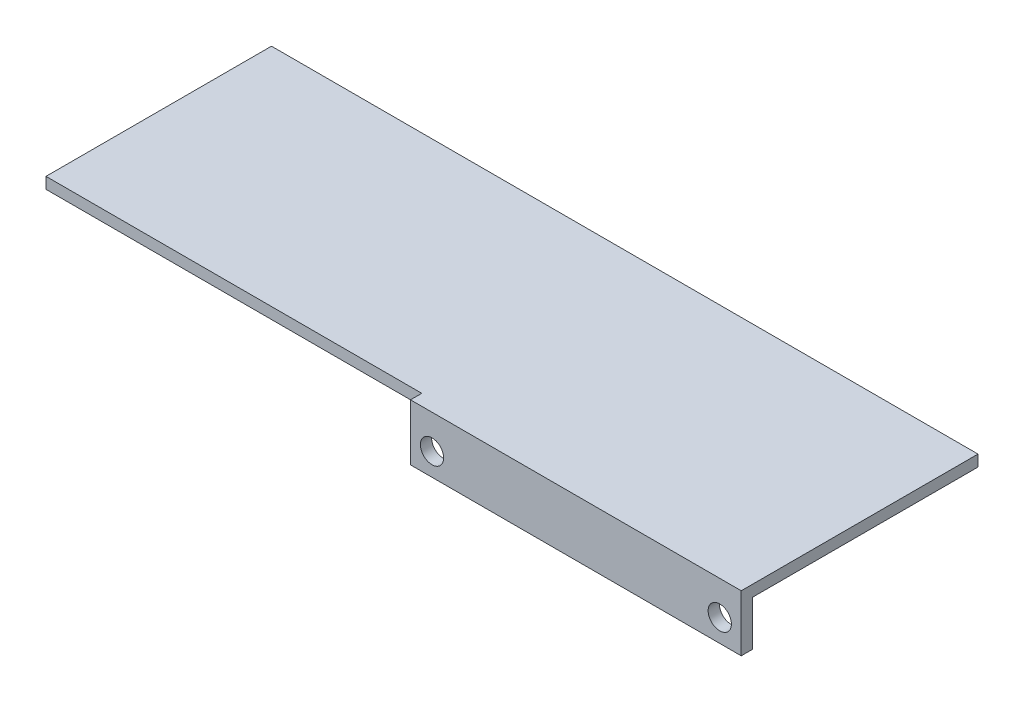
from build123d import *

# Parameters (mm, degrees)
SKETCH_1_W      = 44
SKETCH_1_H      = 6
SKETCH_1_R      = 1.55
EXTRUDE_1_DEPTH = 1.5
SKETCH_2_W      = 44
SKETCH_2_H      = 1.5
EXTRUDE_2_DEPTH = 1.5
SKETCH_4_W      = 44
SKETCH_4_H      = 1.5
EXTRUDE_3_DEPTH = 30
SKETCH_6_W      = 30
SKETCH_6_H      = 1.5
EXTRUDE_4_DEPTH = 50


with BuildPart() as part:
    # 草图1 → 凸台-拉伸1 (new body)
    with BuildSketch(Plane.XY):
        Rectangle(SKETCH_1_W, SKETCH_1_H)
        with Locations((-19.14418972, 0)):
            Circle(SKETCH_1_R, mode=Mode.SUBTRACT)
        with Locations((19.14418972, 0)):
            Circle(SKETCH_1_R, mode=Mode.SUBTRACT)
    extrude(amount=EXTRUDE_1_DEPTH)

    # 草图2 → 凸台-拉伸2 (add)
    with BuildSketch(Plane(origin=(0, 3, 0), x_dir=(1, 0, 0), z_dir=(0, 1, 0))):
        with Locations((0, -0.75)):
            Rectangle(SKETCH_2_W, SKETCH_2_H)
    extrude(amount=EXTRUDE_2_DEPTH)

    # 草图4 → 凸台-拉伸3 (add)
    with BuildSketch(Plane(origin=(0, 0, 0), x_dir=(-1, 0, 0), z_dir=(0, 0, -1))):
        with Locations((0, 3.75)):
            Rectangle(SKETCH_4_W, SKETCH_4_H)
    extrude(amount=EXTRUDE_3_DEPTH)

    # 草图6 → 凸台-拉伸4 (add)
    with BuildSketch(Plane.ZY.offset(22)):
        with Locations((-15, 3.75)):
            Rectangle(SKETCH_6_W, SKETCH_6_H)
    extrude(amount=EXTRUDE_4_DEPTH)


solid = part.part
